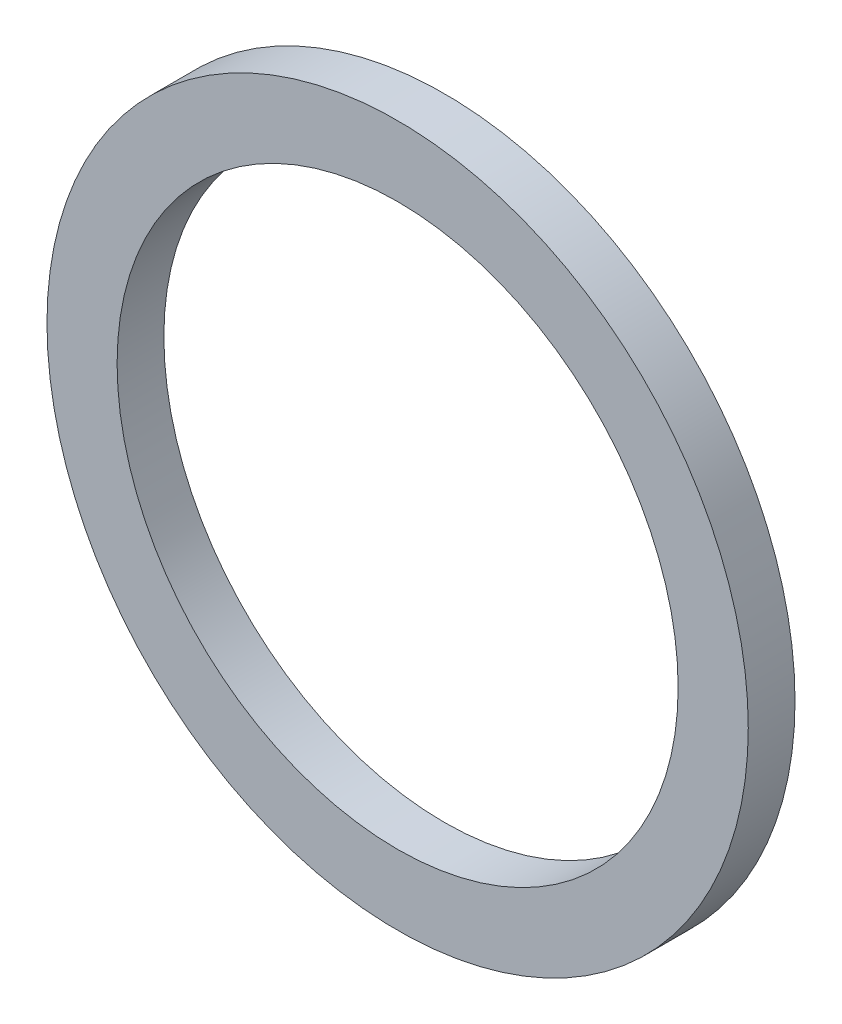
from build123d import *

# Parameters (mm, degrees)
ESQUISSE1_R             = 15
BOSS_EXTRU_1_DEPTH      = 2
ESQUISSE2_R             = 12
ENL_V_MAT_EXTRU_1_DEPTH = 3


with BuildPart() as part:
    # Esquisse1 → Boss.-Extru.1 (new body)
    with BuildSketch(Plane.XY):
        Circle(ESQUISSE1_R)
    extrude(amount=BOSS_EXTRU_1_DEPTH)

    # Esquisse2 → Enlèv. mat.-Extru.1 (cut, through all)
    with BuildSketch(Plane.XY.offset(2)):
        Circle(ESQUISSE2_R)
    extrude(amount=-ENL_V_MAT_EXTRU_1_DEPTH, mode=Mode.SUBTRACT)


solid = part.part
